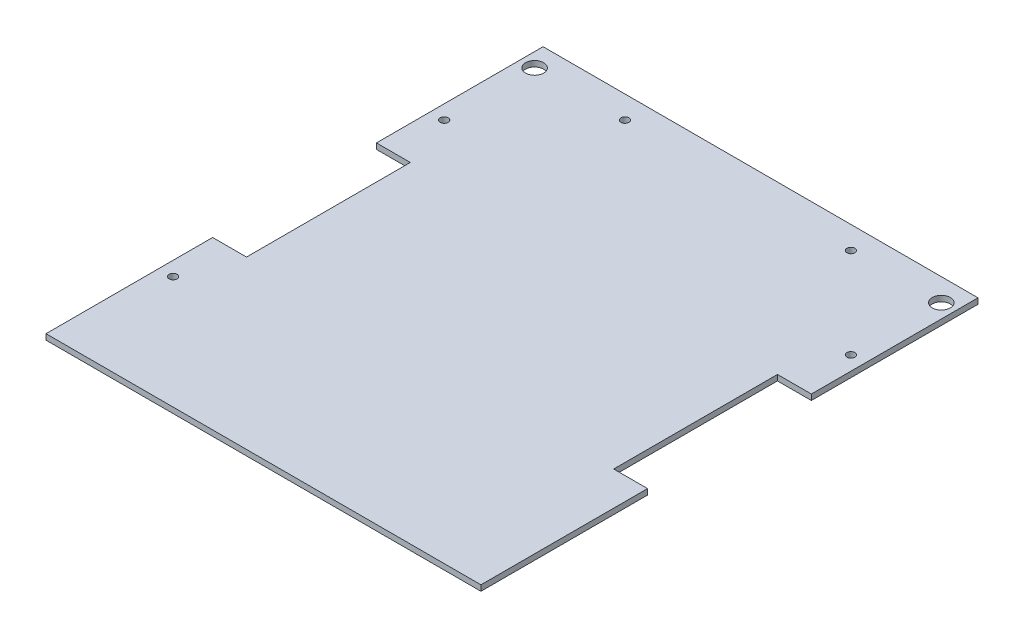
from build123d import *

# Parameters (mm, degrees)
SKETCH1_W           = 457.2
SKETCH1_H           = 279.4
BOSS_EXTRUDE1_DEPTH = 3.175
SKETCH2_R           = 5.08
CUT_EXTRUDE1_DEPTH  = 3.175
SKETCH4_R           = 2.25
CUT_EXTRUDE3_DEPTH  = 25.4
SKETCH6_R           = 2.25
CUT_EXTRUDE5_DEPTH  = 637.032
SKETCH7_R           = 5.08
SKETCH7_R_2         = 2.25
SKETCH7_W           = 1.5875
SKETCH7_H           = 31.75
CUT_EXTRUDE6_DEPTH  = 25.4


with BuildPart() as part:
    # Sketch1 → Boss-Extrude1 (new body)
    with BuildSketch(Plane(origin=(0, 0, 0), x_dir=(1, 0, 0), z_dir=(0, 1, 0))):
        Rectangle(SKETCH1_W, SKETCH1_H)
    extrude(amount=BOSS_EXTRUDE1_DEPTH)

    # Sketch2 → Cut-Extrude1 (cut)
    with BuildSketch(Plane(origin=(0, 3.175, 0), x_dir=(1, 0, 0), z_dir=(0, 1, 0))):
        with Locations((-114.3, 127)):
            Circle(SKETCH2_R)
        with Locations((114.3, 127)):
            Circle(SKETCH2_R)
        with Locations((-215.9, -127)):
            Circle(SKETCH2_R)
        with Locations((215.9, -127)):
            Circle(SKETCH2_R)
        with BuildLine():
            Line((-212.307897552, 130.592102448), (-205.957897552, 124.242102448))
            ThreePointArc((-205.957897552, 124.242102448), (-205.957897552, 117.057897552), (-213.142102448, 117.057897552))
            Line((-213.142102448, 117.057897552), (-219.492102448, 123.407897552))
            ThreePointArc((-219.492102448, 123.407897552), (-219.492102448, 130.592102448), (-212.307897552, 130.592102448))
        make_face()
        with BuildLine():
            Line((212.307897552, 130.592102448), (205.957897552, 124.242102448))
            ThreePointArc((205.957897552, 124.242102448), (205.957897552, 117.057897552), (213.142102448, 117.057897552))
            Line((213.142102448, 117.057897552), (219.492102448, 123.407897552))
            ThreePointArc((219.492102448, 123.407897552), (219.492102448, 130.592102448), (212.307897552, 130.592102448))
        make_face()
    extrude(amount=-CUT_EXTRUDE1_DEPTH, mode=Mode.SUBTRACT)

    # Sketch4 → Cut-Extrude3 (cut)
    with BuildSketch(Plane(origin=(0, 3.175, 0), x_dir=(1, 0, 0), z_dir=(0, 1, 0))):
        with Locations((-196.85, 127)):
            Circle(SKETCH4_R)
        with Locations((-215.9, 107.95)):
            Circle(SKETCH4_R)
        with Locations((196.85, 127)):
            Circle(SKETCH4_R)
        with Locations((215.9, 107.95)):
            Circle(SKETCH4_R)
    extrude(amount=-CUT_EXTRUDE3_DEPTH, mode=Mode.SUBTRACT)

    # Sketch6 → Cut-Extrude5 (cut)
    with BuildSketch(Plane(origin=(0, 3.175, 0), x_dir=(1, 0, 0), z_dir=(0, 1, 0))):
        with Locations((-215.9, 76.2)):
            Circle(SKETCH6_R)
        with Locations((-215.9, 0)):
            Circle(SKETCH6_R)
        with Locations((-215.9, -88.9)):
            Circle(SKETCH6_R)
        with Locations((-114.3, -76.2)):
            Circle(SKETCH6_R)
        with Locations((-114.3, 76.2)):
            Circle(SKETCH6_R)
        with Locations((-63.5, 127)):
            Circle(SKETCH6_R)
        with Locations((63.5, 127)):
            Circle(SKETCH6_R)
        with Locations((114.3, 76.2)):
            Circle(SKETCH6_R)
        with Locations((215.9, -88.9)):
            Circle(SKETCH6_R)
        with Locations((215.9, 0)):
            Circle(SKETCH6_R)
        with Locations((215.9, 76.2)):
            Circle(SKETCH6_R)
    extrude(amount=-CUT_EXTRUDE5_DEPTH, mode=Mode.SUBTRACT)

    # Sketch7 → Cut-Extrude6 (cut)
    with BuildSketch(Plane(origin=(0, 3.175, 0), x_dir=(1, 0, 0), z_dir=(0, 1, 0))):
        Polygon((-104.775, -44.45), (-104.775, 44.45), (-123.825, 44.45), (-123.825, 107.95), (-123.825, 139.7), (-228.6, 139.7), (-228.6, -139.7), (-123.825, -139.7), (-123.825, -107.95), (-123.825, -44.45), align=None)
        with Locations((-215.9, -127)):
            Circle(SKETCH7_R, mode=Mode.SUBTRACT)
        with Locations((-215.9, -88.9)):
            Circle(SKETCH7_R_2, mode=Mode.SUBTRACT)
        with Locations((-215.9, 0)):
            Circle(SKETCH7_R_2, mode=Mode.SUBTRACT)
        with Locations((-114.3, -19.05)):
            Circle(SKETCH7_R_2, mode=Mode.SUBTRACT)
        with Locations((-114.3, 19.05)):
            Circle(SKETCH7_R_2, mode=Mode.SUBTRACT)
        with Locations((-215.9, 76.2)):
            Circle(SKETCH7_R_2, mode=Mode.SUBTRACT)
        with Locations((-215.9, 107.95)):
            Circle(SKETCH7_R_2, mode=Mode.SUBTRACT)
        with BuildLine():
            Line((-213.142102448, 117.057897552), (-219.492102448, 123.407897552))
            ThreePointArc((-219.492102448, 123.407897552), (-219.492102448, 130.592102448), (-212.307897552, 130.592102448))
            Line((-212.307897552, 130.592102448), (-205.957897552, 124.242102448))
            ThreePointArc((-205.957897552, 124.242102448), (-205.957897552, 117.057897552), (-213.142102448, 117.057897552))
        make_face(mode=Mode.SUBTRACT)
        with Locations((-196.85, 127)):
            Circle(SKETCH7_R_2, mode=Mode.SUBTRACT)
        Polygon((228.6, 139.7), (122.2375, 139.7), (122.2375, 107.95), (122.2375, 46.0375), (103.1875, 46.0375), (103.1875, -46.0375), (122.2375, -46.0375), (122.2375, -107.95), (122.2375, -139.7), (228.6, -139.7), align=None)
        with Locations((215.9, -127)):
            Circle(SKETCH7_R, mode=Mode.SUBTRACT)
        with Locations((215.9, -88.9)):
            Circle(SKETCH7_R_2, mode=Mode.SUBTRACT)
        with Locations((215.9, 0)):
            Circle(SKETCH7_R_2, mode=Mode.SUBTRACT)
        with Locations((215.9, 76.2)):
            Circle(SKETCH7_R_2, mode=Mode.SUBTRACT)
        with Locations((215.9, 107.95)):
            Circle(SKETCH7_R_2, mode=Mode.SUBTRACT)
        with Locations((196.85, 127)):
            Circle(SKETCH7_R_2, mode=Mode.SUBTRACT)
        with BuildLine():
            Line((205.957897552, 124.242102448), (212.307897552, 130.592102448))
            ThreePointArc((212.307897552, 130.592102448), (219.492102448, 130.592102448), (219.492102448, 123.407897552))
            Line((219.492102448, 123.407897552), (213.142102448, 117.057897552))
            ThreePointArc((213.142102448, 117.057897552), (205.957897552, 117.057897552), (205.957897552, 124.242102448))
        make_face(mode=Mode.SUBTRACT)
        Polygon((-123.825, 44.45), (-104.775, 44.45), (-104.775, 46.0375), (-122.2375, 46.0375), (-122.2375, 107.95), (-122.2375, 139.7), (-123.825, 139.7), (-123.825, 107.95), align=None)
        Polygon((-104.775, 46.0375), (-104.775, 44.45), (-104.775, -44.45), (-104.775, -46.0375), (-103.1875, -46.0375), (-103.1875, 46.0375), align=None)
        Polygon((-104.775, -46.0375), (-104.775, -44.45), (-123.825, -44.45), (-123.825, -107.95), (-122.2375, -107.95), (-122.2375, -46.0375), align=None)
        with Locations((-123.03125, -123.825)):
            Rectangle(SKETCH7_W, SKETCH7_H)
        with Locations((-114.3, 19.05)):
            Circle(SKETCH7_R_2)
        with Locations((-114.3, -19.05)):
            Circle(SKETCH7_R_2)
    extrude(amount=-CUT_EXTRUDE6_DEPTH, mode=Mode.SUBTRACT)


solid = part.part
